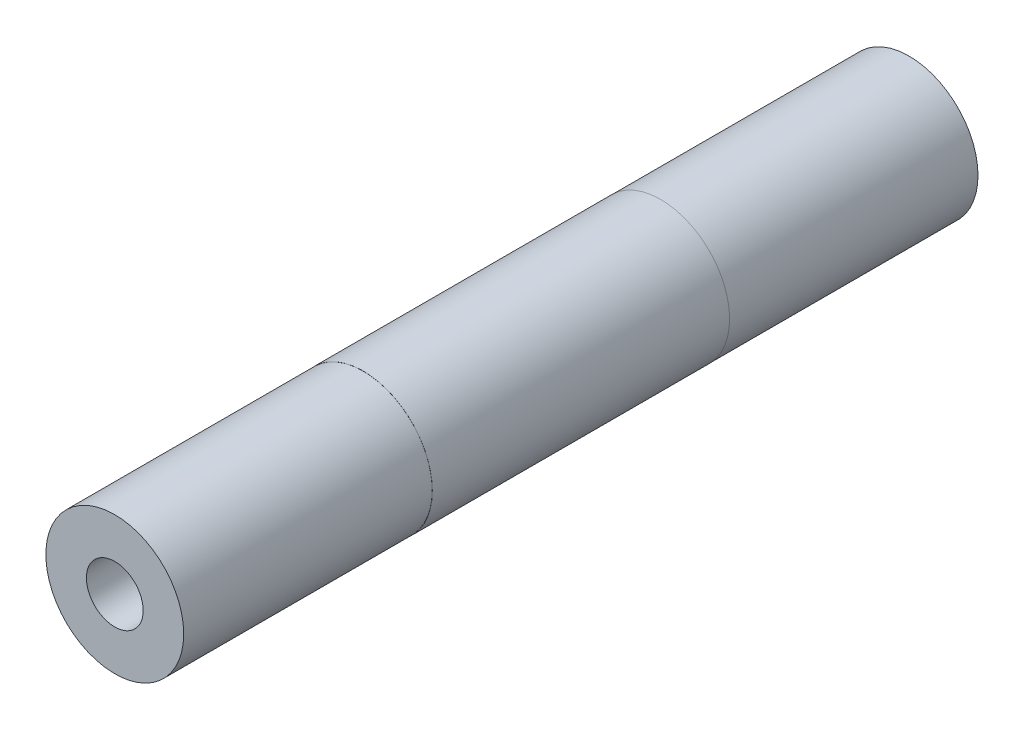
from build123d import *

# Parameters (mm, degrees)
SKETCH1_R                    = 7.9375
EXTRUDE1_DEPTH               = 45.6692
F_5_16_18_TAPPED_HOLE1_D     = 6.5278
F_5_16_18_TAPPED_HOLE1_DEPTH = 20.066
F_5_16_18_TAPPED_HOLE1_TIP   = 1.961148974
F_5_16_18_TAPPED_HOLE2_D     = 6.5278
F_5_16_18_TAPPED_HOLE2_DEPTH = 20.066
F_5_16_18_TAPPED_HOLE2_TIP   = 1.961148974
SKETCH6_R                    = 7.9375
SKETCH6_R_2                  = 7.9248
CUT_EXTRUDE1_DEPTH           = 28.575


with BuildPart() as part:
    # Sketch1 → Extrude1 (new body, symmetric)
    with BuildSketch(Plane.XY):
        Circle(SKETCH1_R)
    extrude(amount=EXTRUDE1_DEPTH, both=True)

    # 5/16-18 Tapped Hole1
    with Locations(Plane.XY.offset(45.6692)):
        with Locations((0, 0)):
            Hole(F_5_16_18_TAPPED_HOLE1_D / 2, depth=F_5_16_18_TAPPED_HOLE1_DEPTH)
            with Locations((0, 0, -(F_5_16_18_TAPPED_HOLE1_DEPTH + F_5_16_18_TAPPED_HOLE1_TIP / 2))):  # 118° drill point
                Cone(0, F_5_16_18_TAPPED_HOLE1_D / 2, F_5_16_18_TAPPED_HOLE1_TIP, mode=Mode.SUBTRACT)

    # 5/16-18 Tapped Hole2
    with Locations(Plane(origin=(0, 0, -45.6692), x_dir=(-1, 0, 0), z_dir=(0, 0, -1))):
        with Locations((0, 0)):
            Hole(F_5_16_18_TAPPED_HOLE2_D / 2, depth=F_5_16_18_TAPPED_HOLE2_DEPTH)
            with Locations((0, 0, -(F_5_16_18_TAPPED_HOLE2_DEPTH + F_5_16_18_TAPPED_HOLE2_TIP / 2))):  # 118° drill point
                Cone(0, F_5_16_18_TAPPED_HOLE2_D / 2, F_5_16_18_TAPPED_HOLE2_TIP, mode=Mode.SUBTRACT)

    # Sketch6 → Cut-Extrude1 (cut)
    with BuildSketch(Plane.XY.offset(45.6692)):
        Circle(SKETCH6_R)
        Circle(SKETCH6_R_2, mode=Mode.SUBTRACT)
    cut_extrude1 = extrude(amount=-CUT_EXTRUDE1_DEPTH, mode=Mode.SUBTRACT)

    # Mirror1: Cut-Extrude1 across plane
    add(cut_extrude1.mirror(Plane.XY), mode=Mode.SUBTRACT)


solid = part.part
